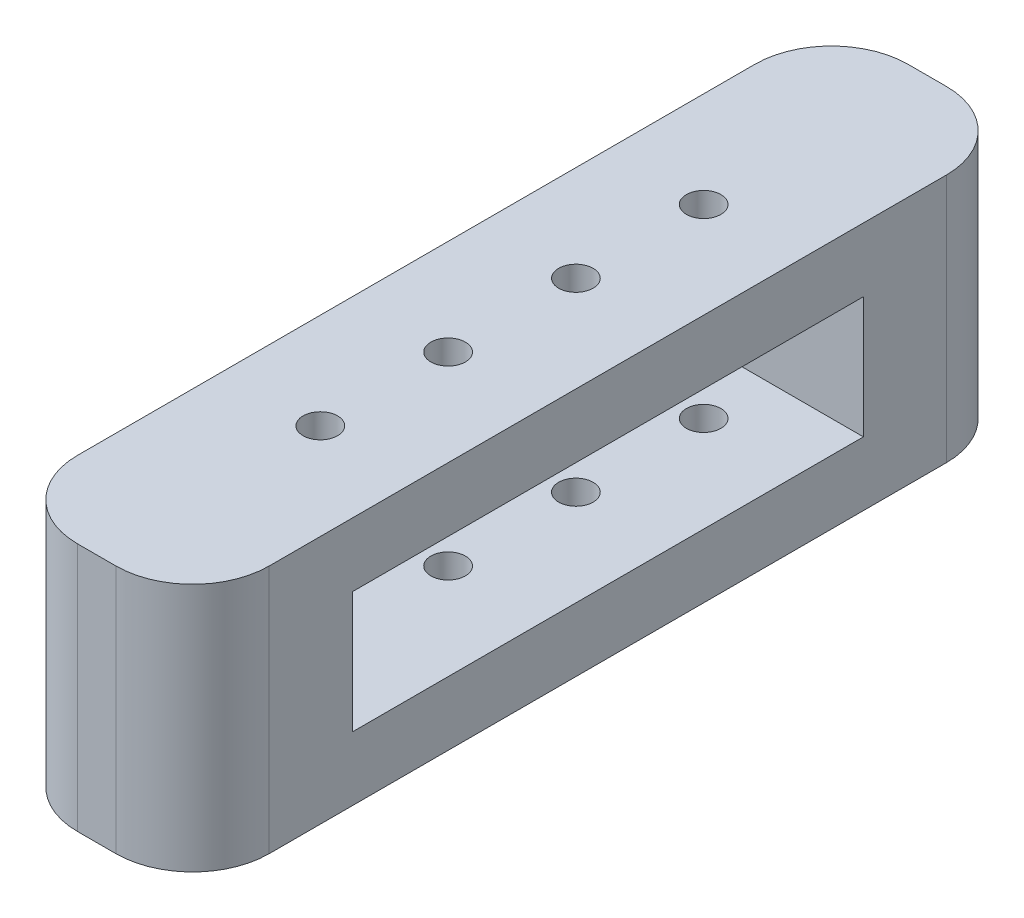
from build123d import *

# Parameters (mm, degrees)
SKETCH1_W           = 15
SKETCH1_H           = 65
SKETCH1_R           = 1.35
BOSS_EXTRUDE1_DEPTH = 19.5
FILLET1_R           = 6
SKETCH2_W           = 40
SKETCH2_H           = 9.5
CUT_EXTRUDE1_DEPTH  = 20


with BuildPart() as part:
    # Sketch1 → Boss-Extrude1 (new body)
    with BuildSketch(Plane(origin=(0, 0, 0), x_dir=(1, 0, 0), z_dir=(0, 1, 0))):
        with Locations((0, -32.5)):
            Rectangle(SKETCH1_W, SKETCH1_H)
        with Locations((0, -17.5)):
            Circle(SKETCH1_R, mode=Mode.SUBTRACT)
        with Locations((0, -27.5)):
            Circle(SKETCH1_R, mode=Mode.SUBTRACT)
        with Locations((0, -37.5)):
            Circle(SKETCH1_R, mode=Mode.SUBTRACT)
        with Locations((0, -47.5)):
            Circle(SKETCH1_R, mode=Mode.SUBTRACT)
    extrude(amount=BOSS_EXTRUDE1_DEPTH)

    # Fillet1
    fillet1_edges = [part.edges().sort_by_distance(p)[0] for p in [
        (-7.5, 9.75, 0),
        (7.5, 9.75, 0),
        (7.5, 9.75, 65),
        (-7.5, 9.75, 65),
    ]]
    fillet(fillet1_edges, radius=FILLET1_R)

    # Sketch2 → Cut-Extrude1 (cut)
    with BuildSketch(Plane.ZY.offset(7.5)):
        with Locations((32.5, 9.75)):
            Rectangle(SKETCH2_W, SKETCH2_H)
    extrude(amount=-CUT_EXTRUDE1_DEPTH, mode=Mode.SUBTRACT)


solid = part.part
